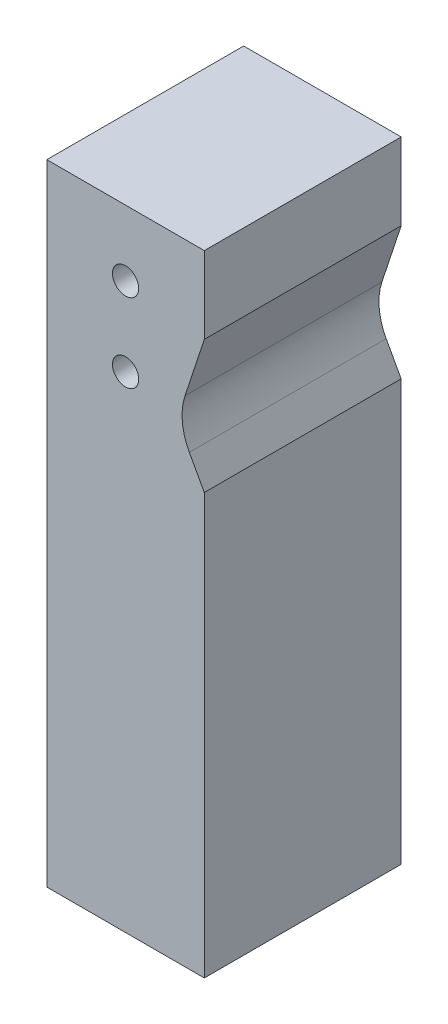
from build123d import *

# Parameters (mm, degrees)
SKETCH1_W           = 19.05
SKETCH1_H           = 76.2
SKETCH1_R           = 1.5875
BOSS_EXTRUDE1_DEPTH = 23.8125
CUT_EXTRUDE1_REACH  = 25.812


with BuildPart() as part:
    # Sketch1 → Boss-Extrude1 (new body)
    with BuildSketch(Plane.XY):
        with Locations((0, -25.4)):
            Rectangle(SKETCH1_W, SKETCH1_H)
        with Locations((0, 4.7625)):
            Circle(SKETCH1_R, mode=Mode.SUBTRACT)
        with Locations((0, -4.7625)):
            Circle(SKETCH1_R, mode=Mode.SUBTRACT)
    extrude(amount=BOSS_EXTRUDE1_DEPTH)

    # Sketch3 → Cut-Extrude1 (cut, up to next)
    with BuildSketch(Plane.XY.offset(23.8125), mode=Mode.PRIVATE) as cut_extrude1_sk1:
        with BuildLine():
            Line((9.525, -12.641309428), (9.525, 3.396941189))
            Line((9.525, 3.396941189), (7.193838245, -3.663696954))
            ThreePointArc((7.193838245, -3.663696954), (6.863457725, -6.55509252), (7.713690054, -9.338332466))
            Line((7.713690054, -9.338332466), (9.525, -12.641309428))
        make_face()
    cut_extrude1_tool1 = extrude(cut_extrude1_sk1.sketch, amount=-CUT_EXTRUDE1_REACH, mode=Mode.PRIVATE) & part.part
    add(cut_extrude1_tool1.solids().sort_by_distance((8.507816, -5.222222, 23.8125))[0], mode=Mode.SUBTRACT)


solid = part.part
